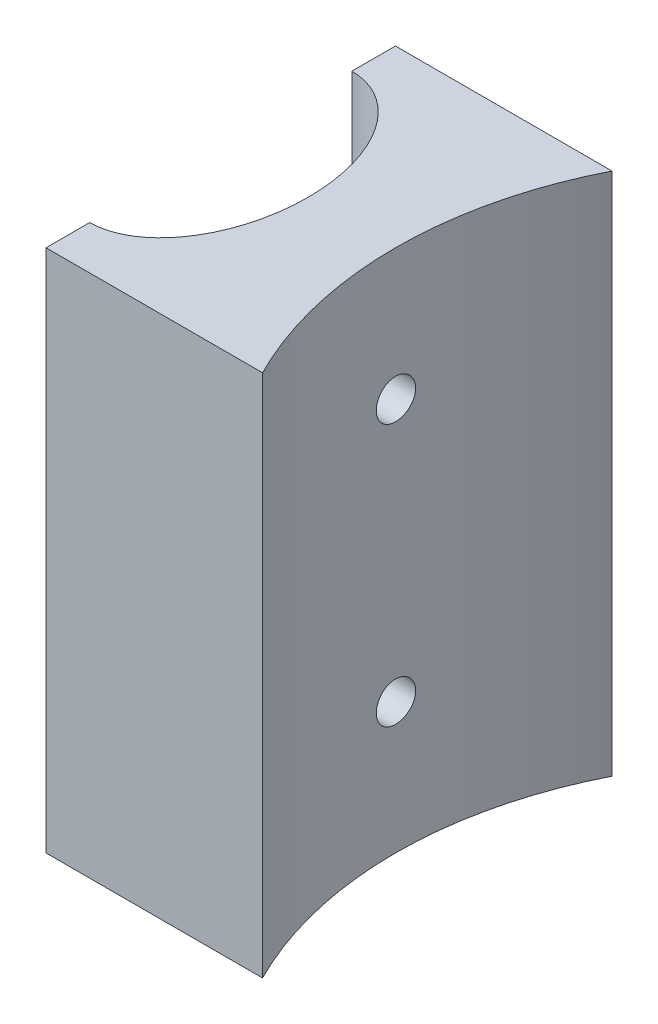
from build123d import *

# Parameters (mm, degrees)
BOSS_EXTRUDE1_DEPTH      = 60
M4_CLEARANCE_HOLE1_D     = 4.5
M4_CLEARANCE_HOLE1_DEPTH = 70
M4_CLEARANCE_HOLE1_TIP   = 1.351936393


with BuildPart() as part:
    # Sketch1 → Boss-Extrude1 (new body)
    with BuildSketch(Plane(origin=(0, 0, 0), x_dir=(1, 0, 0), z_dir=(0, 1, 0))):
        with BuildLine():
            Line((-64.199832154, 20), (-64.199832154, 15))
            add(Edge.make_bspline(
                [(-64.199832154, -15), (-54.199832154, -15), (-54.199832154, 0), (-54.199832154, 15), (-64.199832154, 15)],
                knots=[3.141592654, 3.141592654, 3.141592654, 4.71238898, 4.71238898, 6.283185307, 6.283185307, 6.283185307], degree=2, weights=[1, 0.707106781, 1, 0.707106781, 1]))
            Line((-64.199832154, -15), (-64.199832154, -20))
            Line((-64.199832154, -20), (-39.416052091, -20))
            ThreePointArc((-39.416052091, -20), (-44.199832154, 0), (-39.416052091, 20))
            Line((-39.416052091, 20), (-64.199832154, 20))
        make_face()
    extrude(amount=BOSS_EXTRUDE1_DEPTH)

    # M4 Clearance Hole1
    with Locations(Plane(origin=(0, 0, 0), x_dir=(0, 0, -1), z_dir=(1, 0, 0))):
        with Locations((0, 45), (0, 15)):
            Hole(M4_CLEARANCE_HOLE1_D / 2, depth=M4_CLEARANCE_HOLE1_DEPTH)
            with Locations((0, 0, -(M4_CLEARANCE_HOLE1_DEPTH + M4_CLEARANCE_HOLE1_TIP / 2))):  # 118° drill point
                Cone(0, M4_CLEARANCE_HOLE1_D / 2, M4_CLEARANCE_HOLE1_TIP, mode=Mode.SUBTRACT)


solid = part.part
